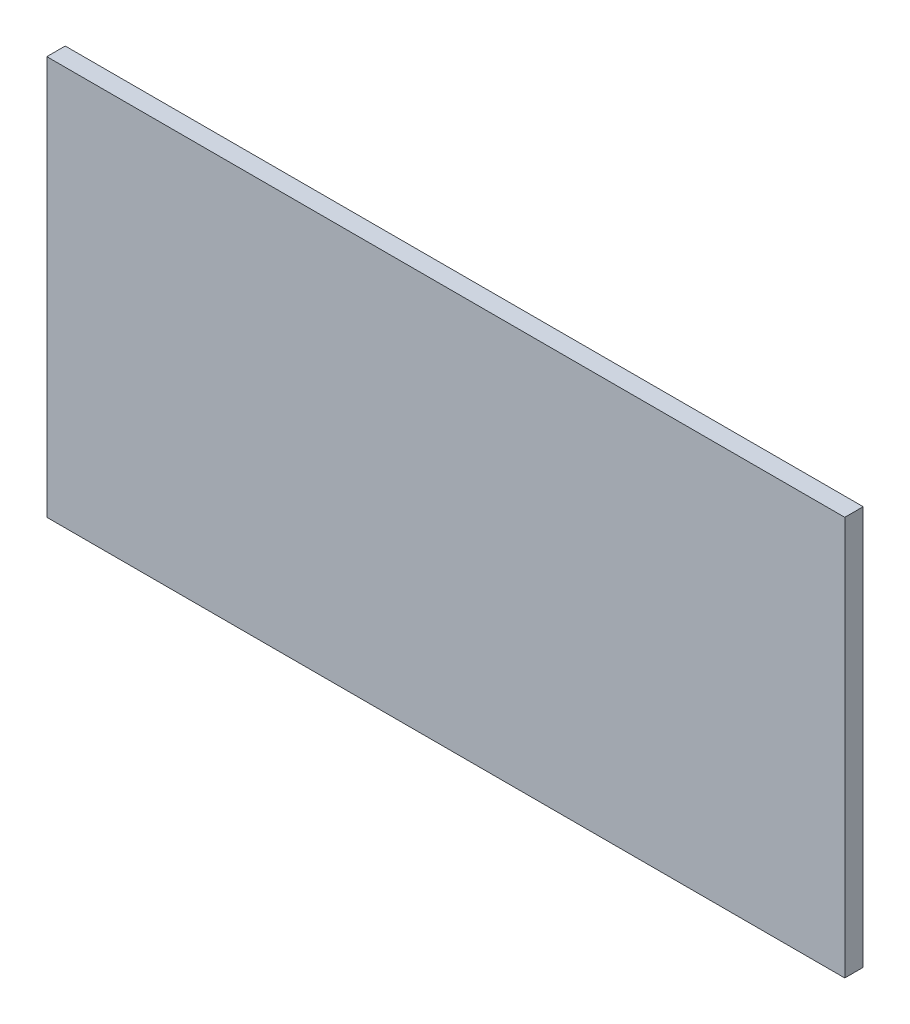
from build123d import *

# Parameters (mm, degrees)
SKETCH_1_W      = 130
SKETCH_1_H      = 65
EXTRUDE_1_DEPTH = 3


with BuildPart() as part:
    # 草图1 → 凸台-拉伸1 (new body)
    with BuildSketch(Plane.XY):
        Rectangle(SKETCH_1_W, SKETCH_1_H)
    extrude(amount=EXTRUDE_1_DEPTH)


solid = part.part
